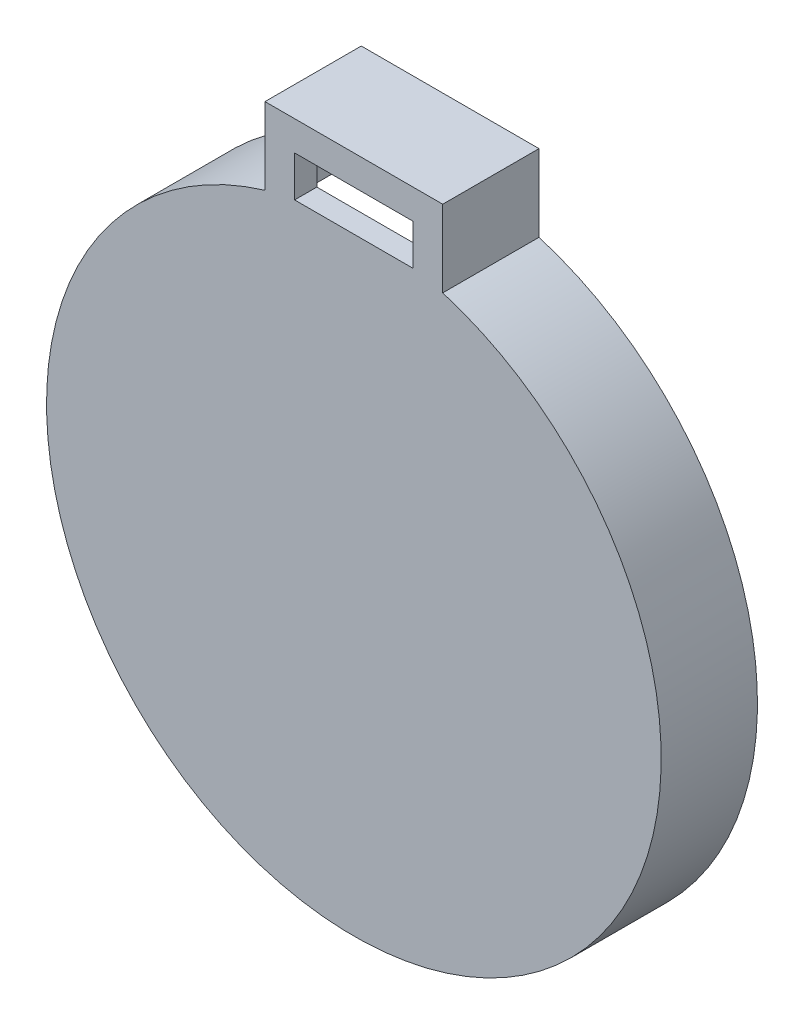
from build123d import *

# Parameters (mm, degrees)
BOSS_EXTRUDE1_DEPTH = 13
BOSS_EXTRUDE2_DEPTH = 3
CUT_EXTRUDE1_START  = -3
SKETCH2_W           = 16
SKETCH2_H           = 5.5
CUT_EXTRUDE1_DEPTH  = 3


with BuildPart() as part:
    # Sketch1 → Boss-Extrude1 (new body)
    with BuildSketch(Plane.XY):
        with BuildLine():
            Line((-10.5, 40.1497198), (-10.5, 48.597279697))
            Line((-10.5, 48.597279697), (10.5, 48.597279697))
            Line((10.5, 48.597279697), (10.5, 40.1497198))
            ThreePointArc((10.5, 40.1497198), (11.251983463, 39.945498722), (12, 39.727194716))
            Line((12, 39.727194716), (12, 50.097279697))
            Line((12, 50.097279697), (-12, 50.097279697))
            Line((-12, 50.097279697), (-12, 39.727194716))
            ThreePointArc((-12, 39.727194716), (-11.251983463, 39.945498722), (-10.5, 40.1497198))
        make_face()
        with BuildLine():
            ThreePointArc((12, 39.727194716), (11.251983463, 39.945498722), (10.5, 40.1497198))
            Line((10.5, 40.1497198), (10.5, 38.597279697))
            ThreePointArc((10.5, 38.597279697), (11.252148087, 38.384751705), (12, 38.157568057))
            Line((12, 38.157568057), (12, 39.727194716))
        make_face()
        with BuildLine():
            Line((-12, 38.157568057), (-12, 39.727194716))
            ThreePointArc((-12, 39.727194716), (-24.741160037, -33.318538383), (41.5, 0))
            ThreePointArc((41.5, 0), (33.318538383, 24.741160037), (12, 39.727194716))
            Line((12, 39.727194716), (12, 38.157568057))
            ThreePointArc((12, 38.157568057), (32.249030993, 23.664319132), (40, 0))
            ThreePointArc((40, 0), (-23.664319132, -32.249030993), (-12, 38.157568057))
        make_face()
        with BuildLine():
            Line((-10.5, 38.597279697), (-10.5, 40.1497198))
            ThreePointArc((-10.5, 40.1497198), (-11.251983463, 39.945498722), (-12, 39.727194716))
            Line((-12, 39.727194716), (-12, 38.157568057))
            ThreePointArc((-12, 38.157568057), (-11.252148087, 38.384751705), (-10.5, 38.597279697))
        make_face()
    extrude(amount=-BOSS_EXTRUDE1_DEPTH)

    # Sketch1_3 → Boss-Extrude2 (add)
    with BuildSketch(Plane.XY):
        with BuildLine():
            Line((-12, 37.097279697), (-12, 38.157568057))
            ThreePointArc((-12, 38.157568057), (-23.664319132, -32.249030993), (40, 0))
            ThreePointArc((40, 0), (32.249030993, 23.664319132), (12, 38.157568057))
            Line((12, 38.157568057), (12, 37.097279697))
            Line((12, 37.097279697), (-12, 37.097279697))
        make_face()
        with BuildLine():
            Line((10.5, 38.597279697), (-10.5, 38.597279697))
            ThreePointArc((-10.5, 38.597279697), (-11.252148087, 38.384751705), (-12, 38.157568057))
            Line((-12, 38.157568057), (-12, 37.097279697))
            Line((-12, 37.097279697), (12, 37.097279697))
            Line((12, 37.097279697), (12, 38.157568057))
            ThreePointArc((12, 38.157568057), (11.252148087, 38.384751705), (10.5, 38.597279697))
        make_face()
        with BuildLine():
            ThreePointArc((10.5, 38.597279697), (0, 40), (-10.5, 38.597279697))
            Line((-10.5, 38.597279697), (10.5, 38.597279697))
        make_face()
        with BuildLine():
            ThreePointArc((10.5, 40.1497198), (0, 41.5), (-10.5, 40.1497198))
            Line((-10.5, 40.1497198), (-10.5, 38.597279697))
            ThreePointArc((-10.5, 38.597279697), (0, 40), (10.5, 38.597279697))
            Line((10.5, 38.597279697), (10.5, 40.1497198))
        make_face()
        with BuildLine():
            Line((10.5, 48.597279697), (-10.5, 48.597279697))
            Line((-10.5, 48.597279697), (-10.5, 40.1497198))
            ThreePointArc((-10.5, 40.1497198), (0, 41.5), (10.5, 40.1497198))
            Line((10.5, 40.1497198), (10.5, 48.597279697))
        make_face()
    extrude(amount=-BOSS_EXTRUDE2_DEPTH)

    # Sketch2 → Cut-Extrude1 (cut)
    with BuildSketch(Plane.XY.offset(CUT_EXTRUDE1_START)):
        with Locations((0, 43.347279697)):
            Rectangle(SKETCH2_W, SKETCH2_H)
    extrude(amount=CUT_EXTRUDE1_DEPTH, mode=Mode.SUBTRACT)


solid = part.part
